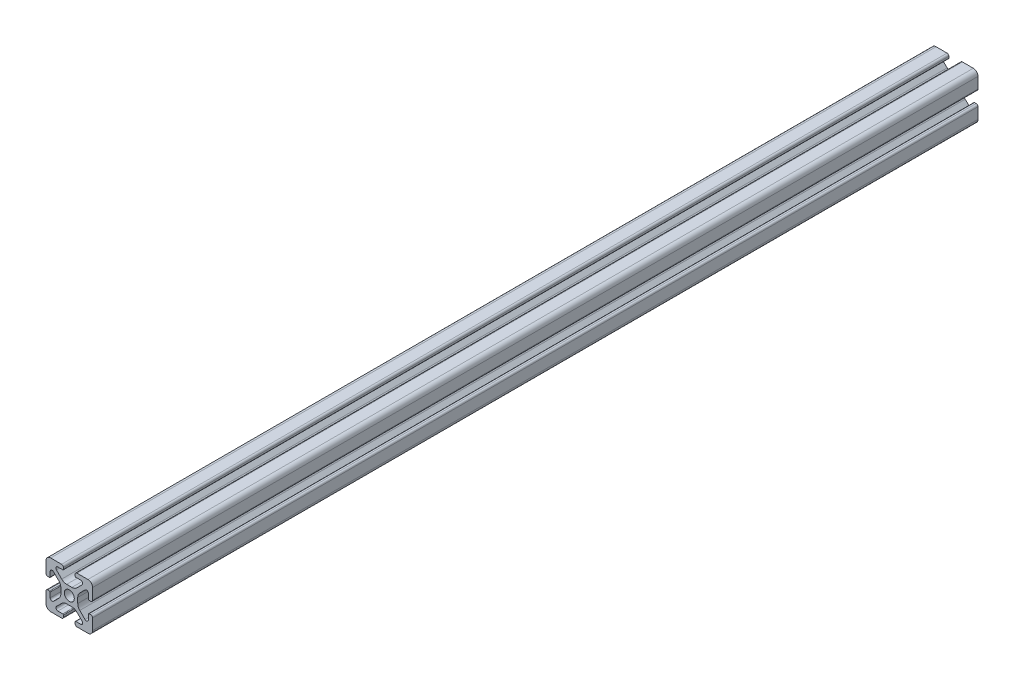
from build123d import *

# Parameters (mm, degrees)
SKETCH1_R           = 2.1463
BOSS_EXTRUDE1_DEPTH = 190.0102


with BuildPart() as part:
    # Sketch1 → Boss-Extrude1 (new body, symmetric)
    with BuildSketch(Plane.XY):
        with BuildLine():
            Line((-9.9949, 7.9883), (-9.9949, 3.2893))
            ThreePointArc((-9.9949, 3.2893), (-9.76427588, 2.73252412), (-9.2075, 2.5019))
            Line((-9.2075, 2.5019), (-8.4963, 2.5019))
            ThreePointArc((-8.4963, 2.5019), (-8.280773853, 2.591173853), (-8.1915, 2.8067))
            Line((-8.1915, 2.8067), (-8.1915, 4.9149))
            ThreePointArc((-8.1915, 4.9149), (-7.674065253, 5.689295824), (-6.760603096, 5.507596904))
            Line((-6.760603096, 5.507596904), (-4.505765747, 3.252759555))
            ThreePointArc((-4.505765747, 3.252759555), (-3.856054457, 2.280397894), (-3.627906192, 1.133419111))
            Line((-3.627906192, 1.133419111), (-3.627906192, -1.133419111))
            ThreePointArc((-3.627906192, -1.133419111), (-3.856054457, -2.280397894), (-4.505765747, -3.252759555))
            Line((-4.505765747, -3.252759555), (-6.760603096, -5.507596904))
            ThreePointArc((-6.760603096, -5.507596904), (-7.674065253, -5.689295824), (-8.1915, -4.9149))
            Line((-8.1915, -4.9149), (-8.1915, -2.8067))
            ThreePointArc((-8.1915, -2.8067), (-8.280773853, -2.591173853), (-8.4963, -2.5019))
            Line((-8.4963, -2.5019), (-9.2075, -2.5019))
            ThreePointArc((-9.2075, -2.5019), (-9.76427588, -2.73252412), (-9.9949, -3.2893))
            Line((-9.9949, -3.2893), (-9.9949, -7.9883))
            ThreePointArc((-9.9949, -7.9883), (-9.407180467, -9.407180467), (-7.9883, -9.9949))
            Line((-7.9883, -9.9949), (-3.2893, -9.9949))
            ThreePointArc((-3.2893, -9.9949), (-2.73252412, -9.76427588), (-2.5019, -9.2075))
            Line((-2.5019, -9.2075), (-2.5019, -8.4963))
            ThreePointArc((-2.5019, -8.4963), (-2.591173853, -8.280773853), (-2.8067, -8.1915))
            Line((-2.8067, -8.1915), (-4.9149, -8.1915))
            ThreePointArc((-4.9149, -8.1915), (-5.689295824, -7.674065253), (-5.507596904, -6.760603096))
            Line((-5.507596904, -6.760603096), (-3.252759555, -4.505765747))
            ThreePointArc((-3.252759555, -4.505765747), (-2.280397894, -3.856054457), (-1.133419111, -3.627906192))
            Line((-1.133419111, -3.627906192), (1.133419111, -3.627906192))
            ThreePointArc((1.133419111, -3.627906192), (2.280397894, -3.856054457), (3.252759555, -4.505765747))
            Line((3.252759555, -4.505765747), (5.507596904, -6.760603096))
            ThreePointArc((5.507596904, -6.760603096), (5.689295824, -7.674065253), (4.9149, -8.1915))
            Line((4.9149, -8.1915), (2.8067, -8.1915))
            ThreePointArc((2.8067, -8.1915), (2.591173853, -8.280773853), (2.5019, -8.4963))
            Line((2.5019, -8.4963), (2.5019, -9.2075))
            ThreePointArc((2.5019, -9.2075), (2.73252412, -9.76427588), (3.2893, -9.9949))
            Line((3.2893, -9.9949), (7.9883, -9.9949))
            ThreePointArc((7.9883, -9.9949), (9.407180467, -9.407180467), (9.9949, -7.9883))
            Line((9.9949, -7.9883), (9.9949, -3.2893))
            ThreePointArc((9.9949, -3.2893), (9.76427588, -2.73252412), (9.2075, -2.5019))
            Line((9.2075, -2.5019), (8.4963, -2.5019))
            ThreePointArc((8.4963, -2.5019), (8.280773853, -2.591173853), (8.1915, -2.8067))
            Line((8.1915, -2.8067), (8.1915, -4.9149))
            ThreePointArc((8.1915, -4.9149), (7.674065253, -5.689295824), (6.760603096, -5.507596904))
            Line((6.760603096, -5.507596904), (4.505765747, -3.252759555))
            ThreePointArc((4.505765747, -3.252759555), (3.856054457, -2.280397894), (3.627906192, -1.133419111))
            Line((3.627906192, -1.133419111), (3.627906192, 1.133419111))
            ThreePointArc((3.627906192, 1.133419111), (3.856054457, 2.280397894), (4.505765747, 3.252759555))
            Line((4.505765747, 3.252759555), (6.760603096, 5.507596904))
            ThreePointArc((6.760603096, 5.507596904), (7.674065253, 5.689295824), (8.1915, 4.9149))
            Line((8.1915, 4.9149), (8.1915, 2.8067))
            ThreePointArc((8.1915, 2.8067), (8.280773853, 2.591173853), (8.4963, 2.5019))
            Line((8.4963, 2.5019), (9.2075, 2.5019))
            ThreePointArc((9.2075, 2.5019), (9.76427588, 2.73252412), (9.9949, 3.2893))
            Line((9.9949, 3.2893), (9.9949, 7.9883))
            ThreePointArc((9.9949, 7.9883), (9.407180467, 9.407180467), (7.9883, 9.9949))
            Line((7.9883, 9.9949), (3.2893, 9.9949))
            ThreePointArc((3.2893, 9.9949), (2.73252412, 9.76427588), (2.5019, 9.2075))
            Line((2.5019, 9.2075), (2.5019, 8.4963))
            ThreePointArc((2.5019, 8.4963), (2.591173853, 8.280773853), (2.8067, 8.1915))
            Line((2.8067, 8.1915), (4.9149, 8.1915))
            ThreePointArc((4.9149, 8.1915), (5.689295824, 7.674065253), (5.507596904, 6.760603096))
            Line((5.507596904, 6.760603096), (3.252759555, 4.505765747))
            ThreePointArc((3.252759555, 4.505765747), (2.280397894, 3.856054457), (1.133419111, 3.627906192))
            Line((1.133419111, 3.627906192), (-1.133419111, 3.627906192))
            ThreePointArc((-1.133419111, 3.627906192), (-2.280397894, 3.856054457), (-3.252759555, 4.505765747))
            Line((-3.252759555, 4.505765747), (-5.507596904, 6.760603096))
            ThreePointArc((-5.507596904, 6.760603096), (-5.689295824, 7.674065253), (-4.9149, 8.1915))
            Line((-4.9149, 8.1915), (-2.8067, 8.1915))
            ThreePointArc((-2.8067, 8.1915), (-2.591173853, 8.280773853), (-2.5019, 8.4963))
            Line((-2.5019, 8.4963), (-2.5019, 9.2075))
            ThreePointArc((-2.5019, 9.2075), (-2.73252412, 9.76427588), (-3.2893, 9.9949))
            Line((-3.2893, 9.9949), (-7.9883, 9.9949))
            ThreePointArc((-7.9883, 9.9949), (-9.407180467, 9.407180467), (-9.9949, 7.9883))
        make_face()
        Circle(SKETCH1_R, mode=Mode.SUBTRACT)
    extrude(amount=BOSS_EXTRUDE1_DEPTH, both=True)


solid = part.part
